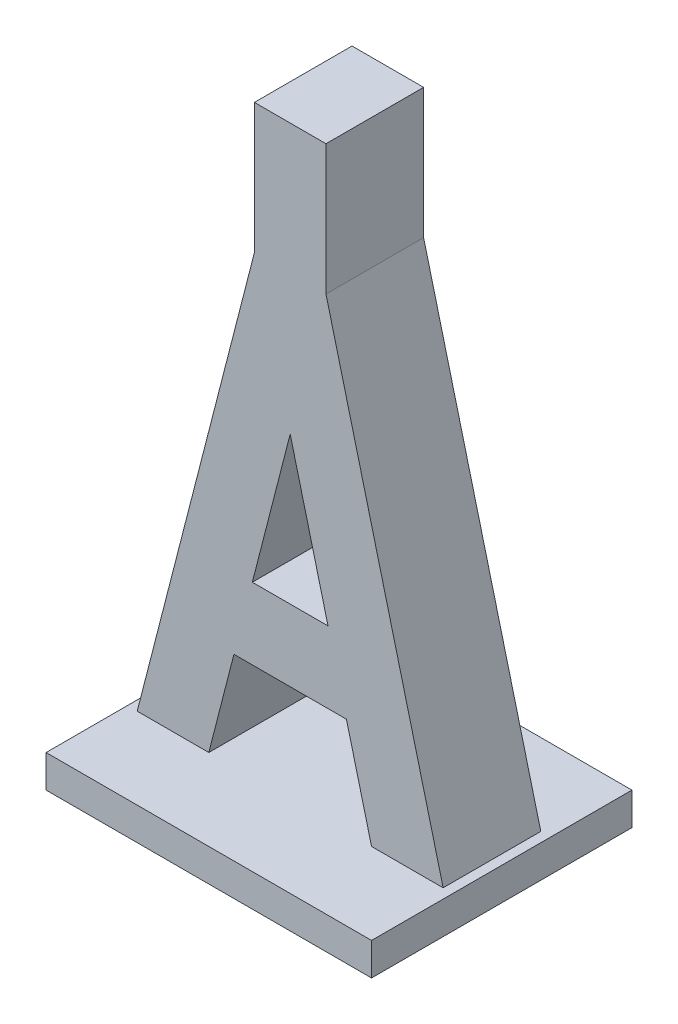
from build123d import *

# Parameters (mm, degrees)
AUFSATZ_LINEAR_AUSTRAGEN1_DEPTH = 15
SKIZZE2_W                       = 50
SKIZZE2_H                       = 40
AUFSATZ_LINEAR_AUSTRAGEN2_DEPTH = 5
SKIZZE3_W                       = 11
SKIZZE3_H                       = 20
AUFSATZ_LINEAR_AUSTRAGEN3_DEPTH = 15


with BuildPart() as part:
    # Skizze1 → Aufsatz-Linear austragen1 (new body)
    with BuildSketch(Plane.XY):
        Polygon((8.642857143, 0), (-8.642857143, 0), (-12.5, -15), (-23.5, -15), (-5.5, 55), (5.5, 55), (23.5, -15), (12.5, -15), align=None)
        Polygon((0, 33.611111111), (-5.814285714, 11), (5.814285714, 11), align=None, mode=Mode.SUBTRACT)
    extrude(amount=AUFSATZ_LINEAR_AUSTRAGEN1_DEPTH)

    # Skizze2 → Aufsatz-Linear austragen2 (add)
    with BuildSketch(Plane.XZ.offset(15)):
        with Locations((0, 7.5)):
            Rectangle(SKIZZE2_W, SKIZZE2_H)
    extrude(amount=AUFSATZ_LINEAR_AUSTRAGEN2_DEPTH)

    # Skizze3 → Aufsatz-Linear austragen3 (add)
    with BuildSketch(Plane.XY.offset(15)):
        with Locations((0, 65)):
            Rectangle(SKIZZE3_W, SKIZZE3_H)
    extrude(amount=-AUFSATZ_LINEAR_AUSTRAGEN3_DEPTH)


solid = part.part
